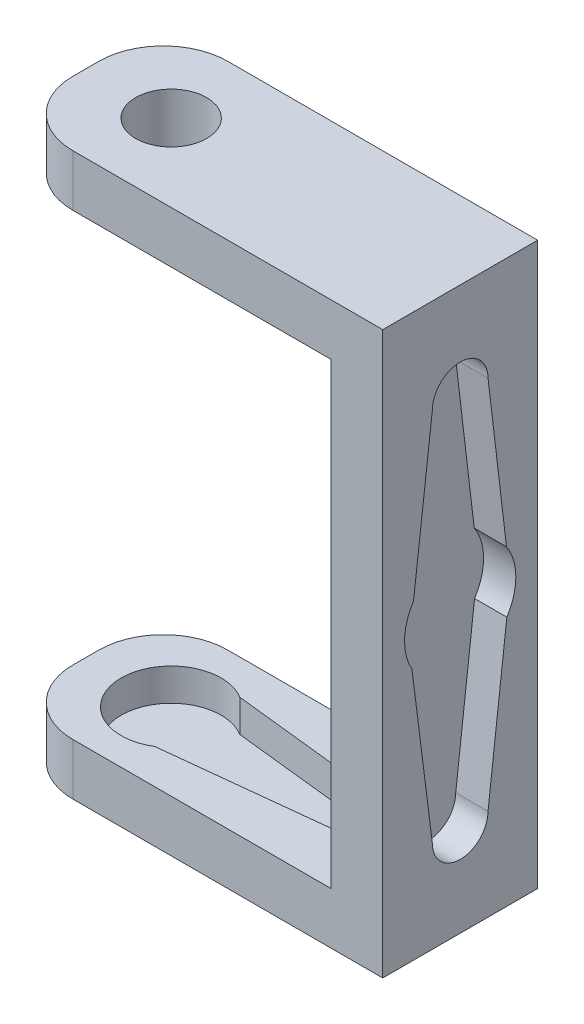
from build123d import *

# Parameters (mm, degrees)
SKETCH3_W           = 25
SKETCH3_H           = 12
BOSS_EXTRUDE1_DEPTH = 4
SINGLE_HORN_DEPTH   = 2.5
SKETCH4_W           = 4
SKETCH4_H           = 12
BOSS_EXTRUDE2_DEPTH = 43.5
SKETCH5_W           = 25
SKETCH5_H           = 12
BOSS_EXTRUDE4_DEPTH = 4
SKETCH6_R           = 2.75
CUT_EXTRUDE3_DEPTH  = 4
FILLET1_R           = 5
DOUBLE_HORN_DEPTH   = 2.5


with BuildPart() as part:
    # Sketch3 → Boss-Extrude1 (new body)
    with BuildSketch(Plane(origin=(0, 0, 0), x_dir=(1, 0, 0), z_dir=(0, 1, 0))):
        with Locations((5.890813757, 0)):
            Rectangle(SKETCH3_W, SKETCH3_H)
    extrude(amount=-BOSS_EXTRUDE1_DEPTH)

    # Sketch1 → single horn (cut)
    with BuildSketch(Plane(origin=(0, 0, 0), x_dir=(1, 0, 0), z_dir=(0, 1, 0))):
        with BuildLine():
            Line((14.254126854, 1.962408156), (2.029090374, 3.299759756))
            ThreePointArc((2.029090374, 3.299759756), (-3.8737091, 0), (2.029090374, -3.299759756))
            Line((2.029090374, -3.299759756), (14.254126854, -1.962408156))
            ThreePointArc((14.254126854, -1.962408156), (16.21653501, 0), (14.254126854, 1.962408156))
        make_face()
    extrude(amount=-SINGLE_HORN_DEPTH, mode=Mode.SUBTRACT)

    # Sketch4 → Boss-Extrude2 (add)
    with BuildSketch(Plane.XZ.offset(4)):
        with Locations((20.390813757, 0)):
            Rectangle(SKETCH4_W, SKETCH4_H)
    extrude(amount=-BOSS_EXTRUDE2_DEPTH)

    # Sketch5 → Boss-Extrude4 (add)
    with BuildSketch(Plane(origin=(0, 39.5, 0), x_dir=(1, 0, 0), z_dir=(0, 1, 0))):
        with Locations((5.890813757, 0)):
            Rectangle(SKETCH5_W, SKETCH5_H)
    extrude(amount=-BOSS_EXTRUDE4_DEPTH)

    # Sketch6 → Cut-Extrude3 (cut)
    with BuildSketch(Plane(origin=(0, 39.5, 0), x_dir=(1, 0, 0), z_dir=(0, 1, 0))):
        Circle(SKETCH6_R)
    extrude(amount=-CUT_EXTRUDE3_DEPTH, mode=Mode.SUBTRACT)

    # Fillet1
    fillet1_edges = [part.edges().sort_by_distance(p)[0] for p in [
        (-6.609186243, 37.5, 6),
        (-6.609186243, 37.5, -6),
        (-6.609186243, -2, -6),
        (-6.609186243, -2, 6),
    ]]
    fillet(fillet1_edges, radius=FILLET1_R)

    # Sketch11 → double horn (cut)
    with BuildSketch(Plane(origin=(22.390813757, 0, 0), x_dir=(0, 0, -1), z_dir=(1, 0, 0))):
        with BuildLine():
            Line((-2.154521604, 32.171561508), (-3.615323039, 20.099129755))
            ThreePointArc((-3.615323039, 20.099129755), (-4.309876098, 17.868064822), (-3.738508691, 15.602321242))
            Line((-3.738508691, 15.602321242), (-2.154521604, 3.109591283))
            ThreePointArc((-2.154521604, 3.109591283), (0.000957171, 0.954112508), (2.156435946, 3.109591283))
            Line((2.156435946, 3.109591283), (3.615323039, 15.400870245))
            ThreePointArc((3.615323039, 15.400870245), (4.311420307, 17.775024288), (3.5878108, 20.140938088))
            Line((3.5878108, 20.140938088), (2.156435946, 32.171561508))
            ThreePointArc((2.156435946, 32.171561508), (0.000957171, 34.327040283), (-2.154521604, 32.171561508))
        make_face()
    extrude(amount=-DOUBLE_HORN_DEPTH, mode=Mode.SUBTRACT)


solid = part.part
